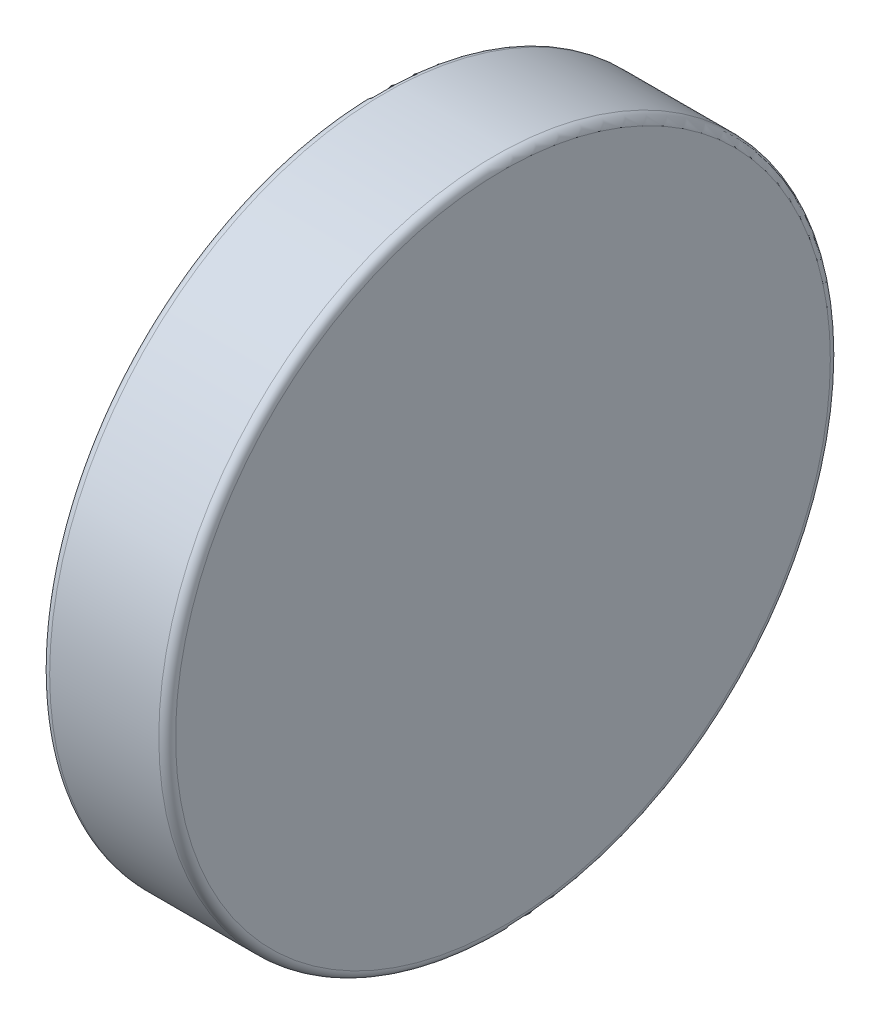
from build123d import *

# Parameters (mm, degrees)
SKETCH1_R           = 4
BOSS_EXTRUDE1_DEPTH = 1.5
FILLET1_R           = 0.1


with BuildPart() as part:
    # Sketch1 → Boss-Extrude1 (new body)
    with BuildSketch(Plane.YZ):
        Circle(SKETCH1_R)
    extrude(amount=BOSS_EXTRUDE1_DEPTH)

    # Fillet1
    fillet1_edges = [part.edges().sort_by_distance(p)[0] for p in [
        (0, -4, 0),
        (1.5, -4, 0),
    ]]
    fillet(fillet1_edges, radius=FILLET1_R)


solid = part.part
